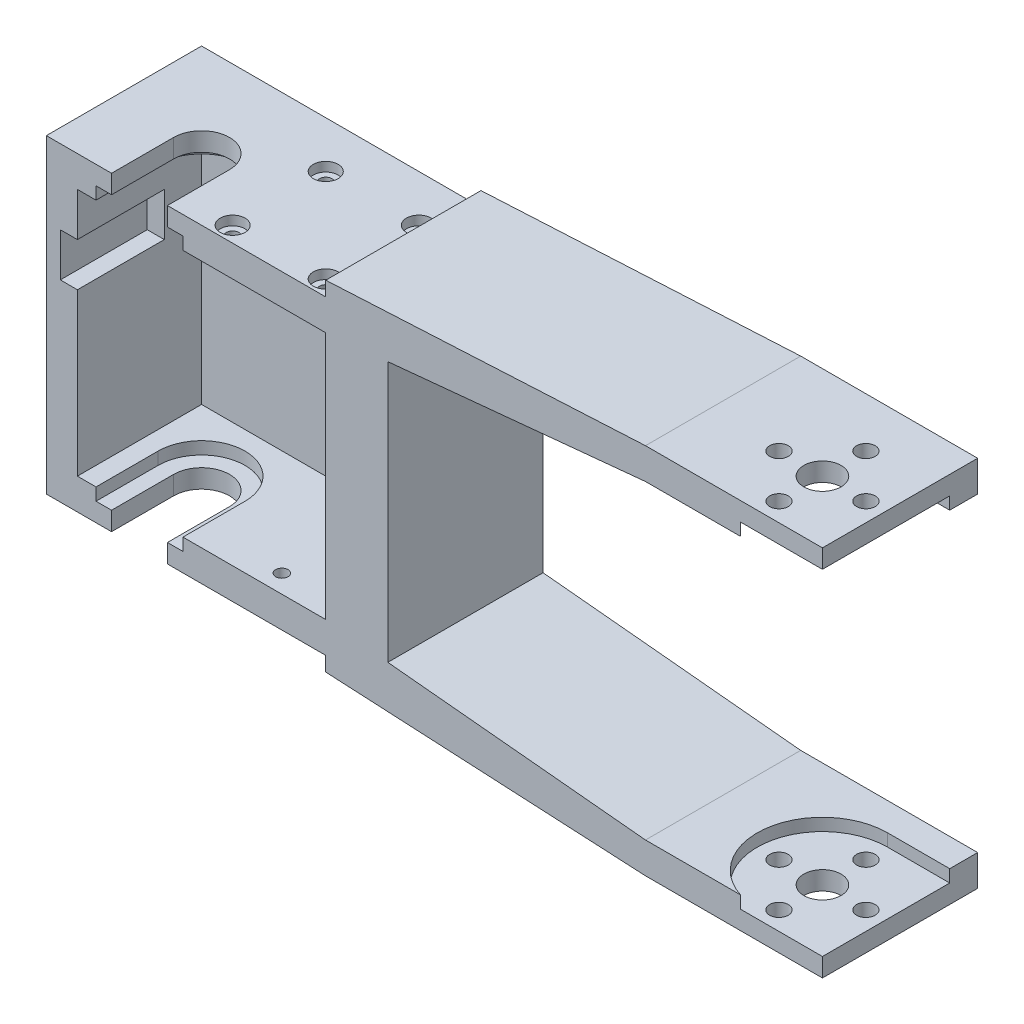
from build123d import *

# Parameters (mm, degrees)
SALIENTE_EXTRUIR2_DEPTH    = 25
CROQUIS4_W                 = 40
CROQUIS4_H                 = 40
CORTAR_EXTRUIR1_DEPTH      = 20
CROQUIS5_R                 = 7
CORTAR_EXTRUIR2_DEPTH      = 42
CORTAR_EXTRUIR2_DEPTH_BACK = 2
CROQUIS6_R                 = 4.5
CORTAR_EXTRUIR3_DEPTH      = 51
CORTAR_EXTRUIR3_DEPTH_BACK = 11
CORTAR_EXTRUIR4_DEPTH      = 26
CROQUIS9_R                 = 1.5
CROQUIS9_R_2               = 3
CORTAR_EXTRUIR6_DEPTH      = 61
CROQUIS10_R                = 1.5
CROQUIS10_R_2              = 3
CORTAR_EXTRUIR7_DEPTH      = 52
CORTAR_EXTRUIR7_DEPTH_BACK = 2
CROQUIS11_W                = 17.982621029
CROQUIS11_H                = 22.653478674
CORTAR_EXTRUIR8_DEPTH      = 52
CORTAR_EXTRUIR8_DEPTH_BACK = 2
CROQUIS13_R                = 1
CORTAR_EXTRUIR9_DEPTH      = 70
CROQUIS14_R                = 1
CORTAR_EXTRUIR10_DEPTH     = 70
CROQUIS15_R                = 2
CORTAR_EXTRUIR11_DEPTH     = 1.5
CROQUIS16_R                = 2
CORTAR_EXTRUIR12_DEPTH     = 1.5
CROQUIS18_W                = 2.75
CROQUIS18_H                = 7
CORTAR_EXTRUIR13_DEPTH     = 14


with BuildPart() as part:
    # Croquis3 → Saliente-Extruir2 (new body)
    with BuildSketch(Plane.XY):
        Polygon((-5, 45), (91.5, 50), (120, 50), (120, 45), (91.5, 45), (91.5, -5), (120, -5), (120, -10), (91.5, -10), (-5, -5), align=None)
    extrude(amount=SALIENTE_EXTRUIR2_DEPTH)

    # Croquis4 → Cortar-Extruir1 (cut)
    with BuildSketch(Plane.XY.offset(25)):
        with Locations((20, 20)):
            Rectangle(CROQUIS4_W, CROQUIS4_H)
    extrude(amount=-CORTAR_EXTRUIR1_DEPTH, mode=Mode.SUBTRACT)

    # Croquis5 → Cortar-Extruir2 (cut, two sides)
    with BuildSketch(Plane.XZ.offset(-40)) as cortar_extruir2_sk:
        with BuildLine():
            ThreePointArc((3, 15), (10, 22), (17, 15))
            Line((17, 15), (17, 25))
            Line((17, 25), (3, 25))
            Line((3, 25), (3, 15))
        make_face()
        with Locations((10, 15)):
            Circle(CROQUIS5_R)
    extrude(amount=CORTAR_EXTRUIR2_DEPTH, mode=Mode.SUBTRACT)
    extrude(cortar_extruir2_sk.sketch, amount=-CORTAR_EXTRUIR2_DEPTH_BACK, mode=Mode.SUBTRACT)

    # Croquis6 → Cortar-Extruir3 (cut, two sides)
    with BuildSketch(Plane.XZ.offset(-40)) as cortar_extruir3_sk:
        with Locations((10, 15)):
            Circle(CROQUIS6_R)
        with BuildLine():
            ThreePointArc((5.5, 15), (10, 19.5), (14.5, 15))
            Line((14.5, 15), (14.5, 25))
            Line((14.5, 25), (5.5, 25))
            Line((5.5, 25), (5.5, 15))
        make_face()
    extrude(amount=CORTAR_EXTRUIR3_DEPTH, mode=Mode.SUBTRACT)
    extrude(cortar_extruir3_sk.sketch, amount=-CORTAR_EXTRUIR3_DEPTH_BACK, mode=Mode.SUBTRACT)

    # Croquis7 → Cortar-Extruir4 (cut, through all)
    with BuildSketch(Plane.XY.offset(25)):
        Polygon((91.5, -5), (50, -0.970873786), (50, 40.970873786), (91.5, 45), align=None)
        Polygon((14.5, 45), (40, 45), (40, 47.331606218), (14.5, 46.010362694), align=None)
        Polygon((14.5, 46.010362694), (40, 47.331606218), (0.618282838, 66.022921742), (-9.359597555, 45), (-5, 45), (14.5, 45), align=None)
        Polygon((40, -7.331606218), (40, -5), (14.5, -5), (14.5, -6.010362694), align=None)
        Polygon((40, -13.475953965), (40, -7.331606218), (14.5, -6.010362694), (14.5, -5), (-5, -5), (-6.220267397, -9.241340311), align=None)
    extrude(amount=-CORTAR_EXTRUIR4_DEPTH, mode=Mode.SUBTRACT)

    # Croquis9 → Cortar-Extruir6 (cut)
    with BuildSketch(Plane(origin=(0, 50, 0), x_dir=(1, 0, 0), z_dir=(0, 1, 0))):
        with Locations((110, -8)):
            Circle(CROQUIS9_R)
        with Locations((110, -15)):
            Circle(CROQUIS9_R_2)
        with Locations((117, -15)):
            Circle(CROQUIS9_R)
        with Locations((110, -22)):
            Circle(CROQUIS9_R)
        with Locations((103, -15)):
            Circle(CROQUIS9_R)
    extrude(amount=-CORTAR_EXTRUIR6_DEPTH, mode=Mode.SUBTRACT)

    # Croquis10 → Cortar-Extruir7 (cut, two sides)
    with BuildSketch(Plane.XZ.offset(-45)) as cortar_extruir7_sk:
        with BuildLine():
            ThreePointArc((120, 18.201562119), (117.424621202, 22.424621202), (113.201562119, 25))
            Line((113.201562119, 25), (106.798437881, 25))
            ThreePointArc((106.798437881, 25), (99.625753039, 13.379814825), (110, 4.5))
            ThreePointArc((110, 4.5), (116.190056452, 6.518655701), (120, 11.798437881))
            Line((120, 11.798437881), (120, 18.201562119))
        make_face()
        with Locations((110, 8)):
            Circle(CROQUIS10_R, mode=Mode.SUBTRACT)
        with Locations((117, 15)):
            Circle(CROQUIS10_R, mode=Mode.SUBTRACT)
        with Locations((103, 15)):
            Circle(CROQUIS10_R, mode=Mode.SUBTRACT)
        with Locations((110, 15)):
            Circle(CROQUIS10_R_2, mode=Mode.SUBTRACT)
        with Locations((110, 22)):
            Circle(CROQUIS10_R, mode=Mode.SUBTRACT)
        with BuildLine():
            Line((132.305371991, 25.5), (110, 25.5))
            ThreePointArc((110, 25.5), (111.620185175, 25.374246961), (113.201562119, 25))
            Line((113.201562119, 25), (120, 25))
            Line((120, 25), (120, 18.201562119))
            ThreePointArc((120, 18.201562119), (120.374246961, 16.620185175), (120.5, 15))
            ThreePointArc((120.5, 15), (120.374246961, 13.379814825), (120, 11.798437881))
            Line((120, 11.798437881), (120, 4.5))
            Line((120, 4.5), (132.305371991, 4.5))
            Line((132.305371991, 4.5), (132.305371991, 25.5))
        make_face()
    extrude(amount=CORTAR_EXTRUIR7_DEPTH, mode=Mode.SUBTRACT)
    extrude(cortar_extruir7_sk.sketch, amount=-CORTAR_EXTRUIR7_DEPTH_BACK, mode=Mode.SUBTRACT)

    # Croquis11 → Cortar-Extruir8 (cut, two sides)
    with BuildSketch(Plane(origin=(0, -5, 0), x_dir=(1, 0, 0), z_dir=(0, 1, 0))) as cortar_extruir8_sk:
        with Locations((118.991310515, -15.826739337)):
            Rectangle(CROQUIS11_W, CROQUIS11_H)
    extrude(amount=CORTAR_EXTRUIR8_DEPTH, mode=Mode.SUBTRACT)
    extrude(cortar_extruir8_sk.sketch, amount=-CORTAR_EXTRUIR8_DEPTH_BACK, mode=Mode.SUBTRACT)

    # Croquis13 → Cortar-Extruir9 (cut)
    with BuildSketch(Plane(origin=(0, 0, 0), x_dir=(1, 0, 0), z_dir=(0, 1, 0))):
        with Locations((37.5, -7.5)):
            Circle(CROQUIS13_R)
        with Locations((37.5, -22.5)):
            Circle(CROQUIS13_R)
        with Locations((22.5, -22.5)):
            Circle(CROQUIS13_R)
        with Locations((22.5, -7.5)):
            Circle(CROQUIS13_R)
    extrude(amount=CORTAR_EXTRUIR9_DEPTH, mode=Mode.SUBTRACT)

    # Croquis14 → Cortar-Extruir10 (cut)
    with BuildSketch(Plane(origin=(0, 0, 0), x_dir=(1, 0, 0), z_dir=(0, 1, 0))):
        with Locations((37.071067812, -15)):
            Circle(CROQUIS14_R)
        with Locations((30, -7.928932188)):
            Circle(CROQUIS14_R)
        with Locations((30, -22.071067812)):
            Circle(CROQUIS14_R)
    extrude(amount=-CORTAR_EXTRUIR10_DEPTH, mode=Mode.SUBTRACT)

    # Croquis15 → Cortar-Extruir11 (cut)
    with BuildSketch(Plane(origin=(0, 45, 0), x_dir=(1, 0, 0), z_dir=(0, 1, 0))):
        with Locations((22.5, -7.5)):
            Circle(CROQUIS15_R)
        with Locations((37.5, -7.5)):
            Circle(CROQUIS15_R)
        with Locations((37.5, -22.5)):
            Circle(CROQUIS15_R)
        with Locations((22.5, -22.5)):
            Circle(CROQUIS15_R)
    extrude(amount=-CORTAR_EXTRUIR11_DEPTH, mode=Mode.SUBTRACT)

    # Croquis16 → Cortar-Extruir12 (cut)
    with BuildSketch(Plane.XZ.offset(5)):
        with Locations((30, 22.071067812)):
            Circle(CROQUIS16_R)
        with Locations((37.071067812, 15)):
            Circle(CROQUIS16_R)
        with Locations((30, 7.928932188)):
            Circle(CROQUIS16_R)
    extrude(amount=-CORTAR_EXTRUIR12_DEPTH, mode=Mode.SUBTRACT)

    # Croquis18 → Cortar-Extruir13 (cut)
    with BuildSketch(Plane.XY.offset(25)):
        with Locations((-1.375, 29.5)):
            Rectangle(CROQUIS18_W, CROQUIS18_H)
    extrude(amount=-CORTAR_EXTRUIR13_DEPTH, mode=Mode.SUBTRACT)


solid = part.part
